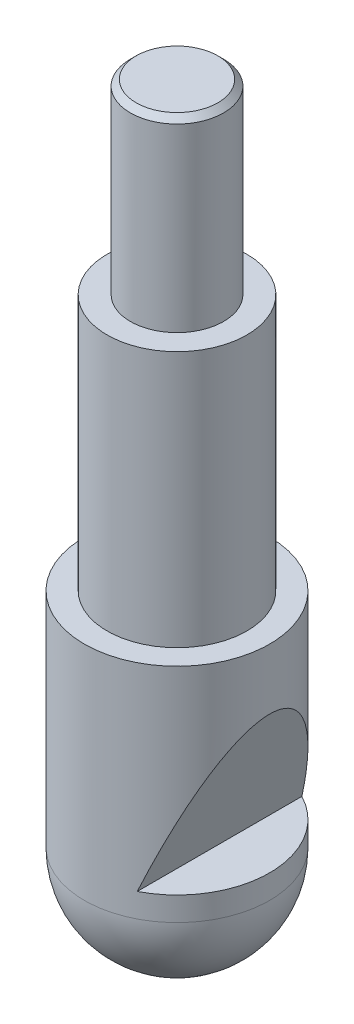
from build123d import *

# Parameters (mm, degrees)
CHANFREIN1_SIZE              = 0.5
ENL_V_MAT_EXTRU_1_DEPTH      = 8.95
ENL_V_MAT_EXTRU_1_DEPTH_BACK = 8.95


with BuildPart() as part:
    # Esquisse1 → Base-Révolution (revolve)
    with BuildSketch(Plane.XY, mode=Mode.PRIVATE) as base_r_volution_sk:
        with BuildLine():
            Line((0, 65), (4, 65))
            Line((4, 65), (4, 49))
            Line((4, 49), (6, 49))
            Line((6, 49), (6, 27))
            Line((6, 27), (7.95, 27))
            Line((7.95, 27), (7.95, 7.95))
            ThreePointArc((7.95, 7.95), (5.62149891, 2.32850109), (0, 0))
            Line((0, 0), (0, 65))
        make_face()
    revolve(base_r_volution_sk.sketch.rotate(Axis((0, -9.281443849, 0), (0, 1, 0)), 90), axis=Axis((0, -9.281443849, 0), (0, 1, 0)))  # turned: the seam where the file's is

    # Chanfrein1
    chanfrein1_edges = [part.edges().sort_by_distance(p)[0] for p in [
        (0, 65, 4),
    ]]
    chamfer(chanfrein1_edges, length=CHANFREIN1_SIZE)

    # Esquisse2 → Enlèv. mat.-Extru.1 (cut, two sides)
    with BuildSketch(Plane.XY) as enl_v_mat_extru_1_sk:
        Polygon((14.617538198, 1), (14.617538198, 10), (3.65, 10), (7.95, 21.8), (23.946768439, 21.8), (23.946768439, -11.083879123), (-11.532407151, -11.083879123), (-11.532407151, 1), align=None)
    extrude(amount=ENL_V_MAT_EXTRU_1_DEPTH, mode=Mode.SUBTRACT)
    extrude(enl_v_mat_extru_1_sk.sketch, amount=-ENL_V_MAT_EXTRU_1_DEPTH_BACK, mode=Mode.SUBTRACT)


solid = part.part
